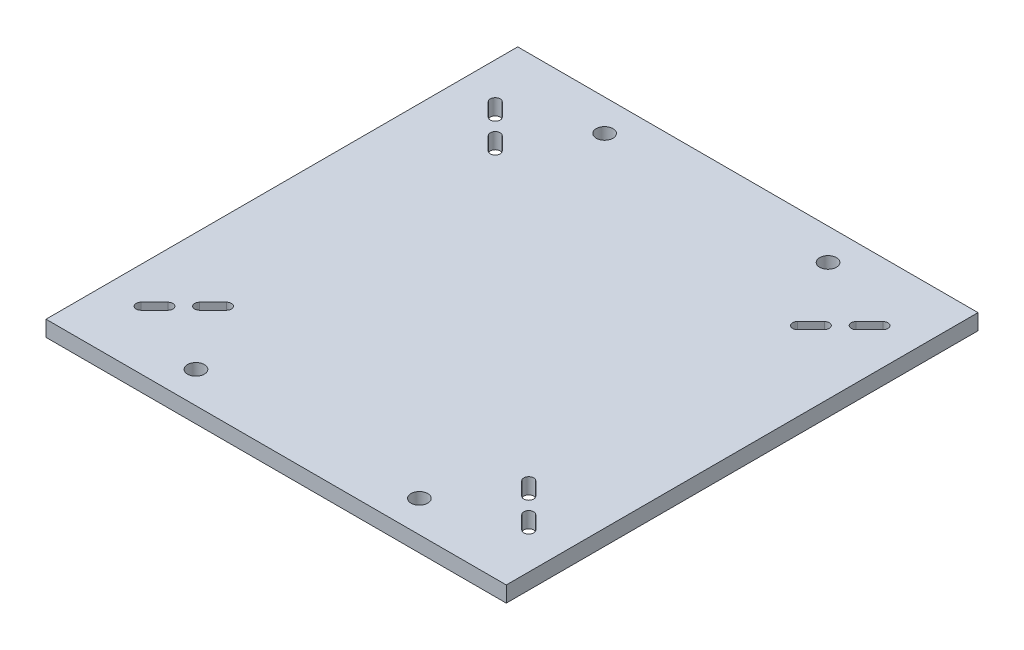
from build123d import *

# Parameters (mm, degrees)
SKETCH1_W              = 185.4
SKETCH1_H              = 190
BASE_PLATE_DEPTH       = 6.35
SLOTS_DEPTH            = 7.35
FEET_CONNECTION_HOLE_D = 6.7564


with BuildPart() as part:
    # Sketch1 → base plate (new body)
    with BuildSketch(Plane(origin=(0, 0, 0), x_dir=(1, 0, 0), z_dir=(0, 1, 0))):
        with Locations((92.7, -95)):
            Rectangle(SKETCH1_W, SKETCH1_H)
    extrude(amount=-BASE_PLATE_DEPTH)

    # Sketch3 → slots (cut, through all)
    with BuildSketch(Plane(origin=(0, 0, 0), x_dir=(1, 0, 0), z_dir=(0, 1, 0))):
        with BuildLine():
            ThreePointArc((21.424612456, -27.64618524), (21.424612456, -30.474612456), (18.59618524, -30.474612456))
            Line((18.59618524, -30.474612456), (13.208031568, -25.086458783))
            ThreePointArc((13.208031568, -25.086458783), (13.208031568, -22.258031568), (16.036458783, -22.258031568))
            Line((16.036458783, -22.258031568), (21.424612456, -27.64618524))
        make_face()
        with BuildLine():
            Line((169.363541217, -22.258031568), (163.975387544, -27.64618524))
            ThreePointArc((163.975387544, -27.64618524), (163.975387544, -30.474612456), (166.80381476, -30.474612456))
            Line((166.80381476, -30.474612456), (172.191968432, -25.086458783))
            ThreePointArc((172.191968432, -25.086458783), (172.191968432, -22.258031568), (169.363541217, -22.258031568))
        make_face()
        with BuildLine():
            Line((154.995131423, -42.283295792), (160.383285096, -36.895142119))
            ThreePointArc((160.383285096, -36.895142119), (160.383285096, -34.066714904), (157.554857881, -34.066714904))
            Line((157.554857881, -34.066714904), (152.166704208, -39.454868577))
            ThreePointArc((152.166704208, -39.454868577), (152.166704208, -42.283295792), (154.995131423, -42.283295792))
        make_face()
        with BuildLine():
            ThreePointArc((160.383285096, -153.104857881), (160.383285096, -155.933285096), (157.554857881, -155.933285096))
            Line((157.554857881, -155.933285096), (152.166704208, -150.545131423))
            ThreePointArc((152.166704208, -150.545131423), (152.166704208, -147.716704208), (154.995131423, -147.716704208))
            Line((154.995131423, -147.716704208), (160.383285096, -153.104857881))
        make_face()
        with BuildLine():
            ThreePointArc((163.975387544, -162.35381476), (163.975387544, -159.525387544), (166.80381476, -159.525387544))
            Line((166.80381476, -159.525387544), (172.191968432, -164.913541217))
            ThreePointArc((172.191968432, -164.913541217), (172.191968432, -167.741968432), (169.363541217, -167.741968432))
            Line((169.363541217, -167.741968432), (163.975387544, -162.35381476))
        make_face()
        with BuildLine():
            Line((16.036458783, -167.741968432), (21.424612456, -162.35381476))
            ThreePointArc((21.424612456, -162.35381476), (21.424612456, -159.525387544), (18.59618524, -159.525387544))
            Line((18.59618524, -159.525387544), (13.208031568, -164.913541217))
            ThreePointArc((13.208031568, -164.913541217), (13.208031568, -167.741968432), (16.036458783, -167.741968432))
        make_face()
        with BuildLine():
            Line((30.404868577, -147.716704208), (25.016714904, -153.104857881))
            ThreePointArc((25.016714904, -153.104857881), (25.016714904, -155.933285096), (27.845142119, -155.933285096))
            Line((27.845142119, -155.933285096), (33.233295792, -150.545131423))
            ThreePointArc((33.233295792, -150.545131423), (33.233295792, -147.716704208), (30.404868577, -147.716704208))
        make_face()
        with BuildLine():
            Line((30.404868577, -42.283295792), (25.016714904, -36.895142119))
            ThreePointArc((25.016714904, -36.895142119), (25.016714904, -34.066714904), (27.845142119, -34.066714904))
            Line((27.845142119, -34.066714904), (33.233295792, -39.454868577))
            ThreePointArc((33.233295792, -39.454868577), (33.233295792, -42.283295792), (30.404868577, -42.283295792))
        make_face()
    extrude(amount=-SLOTS_DEPTH, mode=Mode.SUBTRACT)

    # Feet connection hole (through all)
    with Locations(Plane(origin=(0, 0, 0), x_dir=(1, 0, 0), z_dir=(0, 1, 0))):
        with Locations((47.7, -177.3), (137.7, -12.7), (47.7, -12.7), (137.7, -177.3)):
            Hole(FEET_CONNECTION_HOLE_D / 2)


solid = part.part
